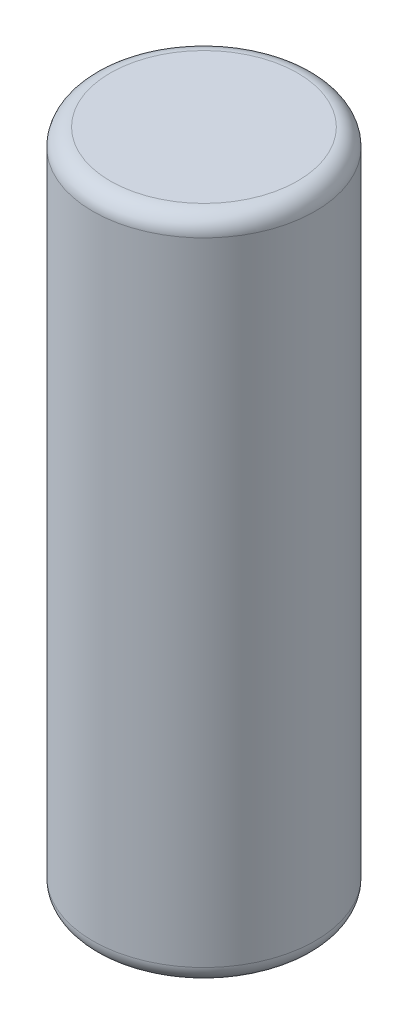
from build123d import *

# Parameters (mm, degrees)
SKETCH1_R           = 3.175
BOSS_EXTRUDE1_DEPTH = 19.05
FILLET1_R           = 0.5


with BuildPart() as part:
    # Sketch1 → Boss-Extrude1 (new body)
    with BuildSketch(Plane(origin=(0, 0, 0), x_dir=(1, 0, 0), z_dir=(0, 1, 0))):
        with Locations(Location((0, 0, 0), (0, 0, 270))):  # turned: the seam where the file's is
            Circle(SKETCH1_R)
    extrude(amount=BOSS_EXTRUDE1_DEPTH)

    # Fillet1
    fillet1_edges = [part.edges().sort_by_distance(p)[0] for p in [
        (0, 0, -3.175),
        (0, 19.05, -3.175),
    ]]
    fillet(fillet1_edges, radius=FILLET1_R)


solid = part.part
